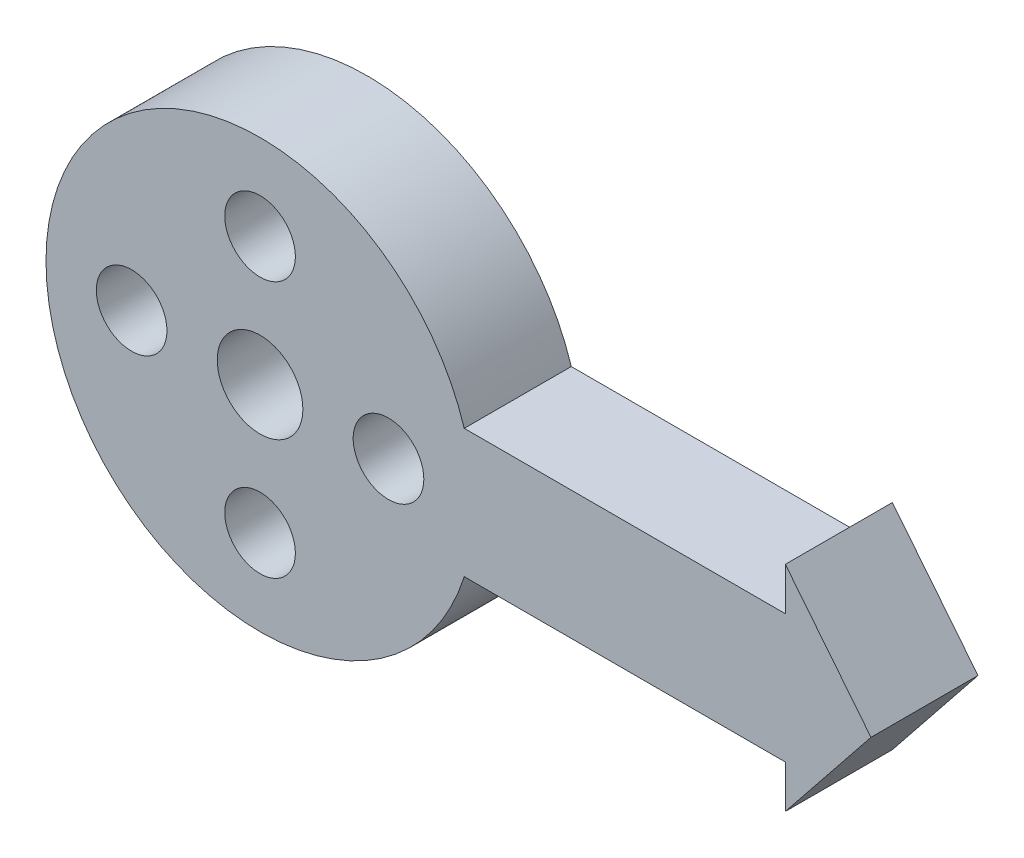
from build123d import *

# Parameters (mm, degrees)
SKETCH1_R           = 2
SKETCH1_R_2         = 1.65
BOSS_EXTRUDE1_DEPTH = 5


with BuildPart() as part:
    # Sketch1 → Boss-Extrude1 (new body)
    with BuildSketch(Plane.XY):
        with BuildLine():
            Line((9.539392014, 3), (24.539392014, 3))
            Line((24.539392014, 3), (24.539392014, 5))
            Line((24.539392014, 5), (28.539392014, 0))
            Line((28.539392014, 0), (24.539392014, -5))
            Line((24.539392014, -5), (24.539392014, -3))
            Line((24.539392014, -3), (9.539392014, -3))
            ThreePointArc((9.539392014, -3), (-10, 0), (9.539392014, 3))
        make_face()
        Circle(SKETCH1_R, mode=Mode.SUBTRACT)
        with Locations((0, 6)):
            Circle(SKETCH1_R_2, mode=Mode.SUBTRACT)
        with Locations((6, 0)):
            Circle(SKETCH1_R_2, mode=Mode.SUBTRACT)
        with Locations((0, -6)):
            Circle(SKETCH1_R_2, mode=Mode.SUBTRACT)
        with Locations((-6, 0)):
            Circle(SKETCH1_R_2, mode=Mode.SUBTRACT)
    extrude(amount=BOSS_EXTRUDE1_DEPTH)


solid = part.part
